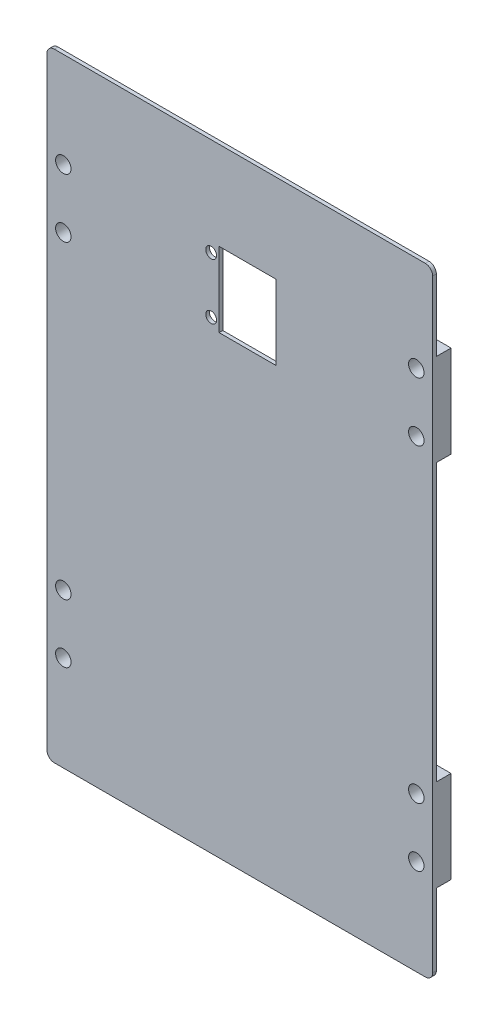
from build123d import *

# Parameters (mm, degrees)
BOSS_EXTRUDE1_START = 4
SKETCH1_W           = 104.9
SKETCH1_H           = 168.1
BOSS_EXTRUDE1_DEPTH = 1
SKETCH2_W           = 8.9
SKETCH2_H           = 25
BOSS_EXTRUDE2_DEPTH = 4
SKETCH5_R           = 2.1
CUT_EXTRUDE5_DEPTH  = 6
CUT_EXTRUDE3_REACH  = 7
SKETCH3_R           = 1.475
SKETCH3_W           = 15.52
SKETCH3_H           = 20.32
FILLET1_R           = 2


with BuildPart() as part:
    # Sketch1 → Boss-Extrude1 (new body)
    with BuildSketch(Plane.XY.offset(BOSS_EXTRUDE1_START)):
        with Locations((52.45, -16.15)):
            Rectangle(SKETCH1_W, SKETCH1_H)
    extrude(amount=BOSS_EXTRUDE1_DEPTH)

    # Sketch2 → Boss-Extrude2 (add)
    with BuildSketch(Plane(origin=(0, 0, 4), x_dir=(-1, 0, 0), z_dir=(0, 0, -1))):
        with Locations((-100.45, 33.95)):
            Rectangle(SKETCH2_W, SKETCH2_H)
        with Locations((-4.45, 33.95)):
            Rectangle(SKETCH2_W, SKETCH2_H)
        with Locations((-4.45, -66.25)):
            Rectangle(SKETCH2_W, SKETCH2_H)
        with Locations((-100.45, -66.25)):
            Rectangle(SKETCH2_W, SKETCH2_H)
    extrude(amount=BOSS_EXTRUDE2_DEPTH)

    # Sketch5 → Cut-Extrude5 (cut, through all)
    with BuildSketch(Plane.XY.offset(5)):
        with Locations((100.45, -74.25)):
            Circle(SKETCH5_R)
        with Locations((100.45, -58.25)):
            Circle(SKETCH5_R)
        with Locations((4.45, -74.25)):
            Circle(SKETCH5_R)
        with Locations((4.45, -58.25)):
            Circle(SKETCH5_R)
        with Locations((4.45, 25.95)):
            Circle(SKETCH5_R)
        with Locations((4.45, 41.95)):
            Circle(SKETCH5_R)
        with Locations((100.45, 25.95)):
            Circle(SKETCH5_R)
        with Locations((100.45, 41.95)):
            Circle(SKETCH5_R)
    extrude(amount=-CUT_EXTRUDE5_DEPTH, mode=Mode.SUBTRACT)

    # Sketch3 → Cut-Extrude3 (cut, up to next)
    with BuildSketch(Plane.XY.offset(5), mode=Mode.PRIVATE) as cut_extrude3_sk1:
        with Locations((44.661, 26.076)):
            Circle(SKETCH3_R)
    cut_extrude3_tool1 = extrude(cut_extrude3_sk1.sketch, amount=-CUT_EXTRUDE3_REACH, mode=Mode.PRIVATE) & part.part
    add(cut_extrude3_tool1.solids().sort_by_distance((44.661, 26.076, 5))[0], mode=Mode.SUBTRACT)
    # Sketch3 → Cut-Extrude3 (cut, up to next)
    with BuildSketch(Plane.XY.offset(5), mode=Mode.PRIVATE) as cut_extrude3_sk2:
        with Locations((44.661, 41.316)):
            Circle(SKETCH3_R)
    cut_extrude3_tool2 = extrude(cut_extrude3_sk2.sketch, amount=-CUT_EXTRUDE3_REACH, mode=Mode.PRIVATE) & part.part
    add(cut_extrude3_tool2.solids().sort_by_distance((44.661, 41.316, 5))[0], mode=Mode.SUBTRACT)
    # Sketch3 → Cut-Extrude3 (cut, up to next)
    with BuildSketch(Plane.XY.offset(5), mode=Mode.PRIVATE) as cut_extrude3_sk3:
        with Locations((54.596, 33.696)):
            Rectangle(SKETCH3_W, SKETCH3_H)
    cut_extrude3_tool3 = extrude(cut_extrude3_sk3.sketch, amount=-CUT_EXTRUDE3_REACH, mode=Mode.PRIVATE) & part.part
    add(cut_extrude3_tool3.solids().sort_by_distance((54.596, 33.696, 5))[0], mode=Mode.SUBTRACT)

    # Fillet1
    fillet1_edges = [part.edges().sort_by_distance(p)[0] for p in [
        (0, 67.9, 4.5),
        (104.9, 67.9, 4.5),
        (104.9, -100.2, 4.5),
        (0, -100.2, 4.5),
    ]]
    fillet(fillet1_edges, radius=FILLET1_R)


solid = part.part
